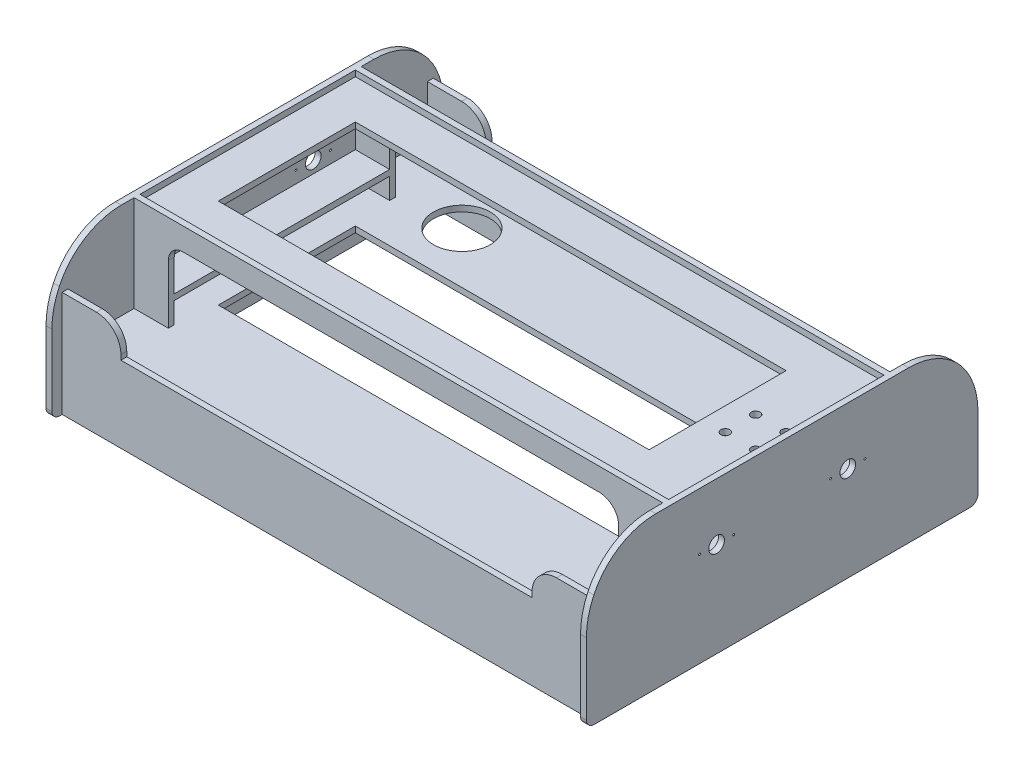
from build123d import *

# Parameters (mm, degrees)
SKETCH_2_W           = 432
SKETCH_2_H           = 220
EXTRUDE_2_DEPTH      = 6
SKETCH_4_W           = 6
SKETCH_4_H           = 28
EXTRUDE_3_DEPTH      = 432
EXTRUDE_4_DEPTH      = 108
SKETCH_6_W           = 540
SKETCH_6_H           = 6
EXTRUDE_5_DEPTH      = 25
EXTRUDE_6_DEPTH      = 6
EXTRUDE_7_DEPTH      = 6
SKETCH_9_W           = 367
SKETCH_9_H           = 6
EXTRUDE_8_DEPTH      = 540
SKETCH_10_R          = 8
CUT_EXTRUDE_1_DEPTH  = 553
SKETCH_11_W          = 6
SKETCH_11_H          = 108
EXTRUDE_9_DEPTH      = 546
SKETCH_12_W          = 70
SKETCH_12_H          = 127
SKETCH_12_W_2        = 195
CUT_EXTRUDE_2_DEPTH  = 6
SKETCH_13_R          = 29
SKETCH_13_W          = 42.3
SKETCH_13_H          = 42.3
CUT_EXTRUDE_3_DEPTH  = 10
SKETCH_14_W          = 220
SKETCH_14_H          = 6
EXTRUDE_10_DEPTH     = 45
SKETCH_15_R          = 16.4
SKETCH_15_R_2        = 1.5
CUT_EXTRUDE_4_DEPTH  = 6
SKETCH_16_R          = 4.5
CUT_EXTRUDE_5_DEPTH  = 6
FILLET_1_R           = 80
FILLET_2_R           = 8
SKETCH_18_W          = 6
SKETCH_18_H          = 75
EXTRUDE_11_DEPTH     = 45
SKETCH_19_W          = 420
SKETCH_19_H          = 30
SKETCH_19_W_2        = 540
CUT_EXTRUDE_8_DEPTH  = 390.5
FILLET_4_R           = 25
FILLET_6_R           = 20
SKETCH_20_W          = 6
SKETCH_20_H          = 75
EXTRUDE_12_DEPTH     = 35
FILLET_7_R           = 15
SKETCH_21_W          = 220
SKETCH_21_H          = 6
EXTRUDE_13_DEPTH     = 35
SKETCH_22_R          = 1
CUT_EXTRUDE_9_DEPTH  = 553
CUT_EXTRUDE_10_DEPTH = 58
SKETCH_24_W          = 440
SKETCH_24_H          = 140
CUT_EXTRUDE_11_DEPTH = 150
SKETCH_25_W          = 309.538461538
SKETCH_25_H          = 30
CUT_EXTRUDE_12_DEPTH = 553
FILLET_8_R           = 70


with BuildPart() as part:
    # Эскиз2 → Бобышка-Вытянуть2 (new body)
    with BuildSketch(Plane(origin=(0, 0, 0), x_dir=(1, 0, 0), z_dir=(0, 1, 0))):
        Rectangle(SKETCH_2_W, SKETCH_2_H)
    extrude(amount=EXTRUDE_2_DEPTH)

    # Эскиз4 → Бобышка-Вытянуть3 (add)
    with BuildSketch(Plane(origin=(216, 0, 0), x_dir=(0, 0, -1), z_dir=(1, 0, 0))):
        with Locations((-113, 3)):
            Rectangle(SKETCH_4_W, SKETCH_4_H)
        with Locations((113, 3)):
            Rectangle(SKETCH_4_W, SKETCH_4_H)
    extrude(amount=-EXTRUDE_3_DEPTH)

    # Эскиз5 → Бобышка-Вытянуть4 (add)
    with BuildSketch(Plane.ZY.offset(216)):
        Polygon((-116, 17), (-110, 17), (-110, 6), (110, 6), (110, 17), (116, 17), (116, -11), (110, -11), (110, 0), (-110, 0), (-110, -11), (-116, -11), align=None)
    extrude(amount=EXTRUDE_4_DEPTH)

    # Эскиз6 → Бобышка-Вытянуть5 (add)
    with BuildSketch(Plane(origin=(0, 17, 0), x_dir=(1, 0, 0), z_dir=(0, 1, 0))):
        with Locations((-54, -113)):
            Rectangle(SKETCH_6_W, SKETCH_6_H)
        with Locations((-54, 113)):
            Rectangle(SKETCH_6_W, SKETCH_6_H)
    extrude(amount=EXTRUDE_5_DEPTH)

    # Эскиз7 → Бобышка-Вытянуть6 (add)
    with BuildSketch(Plane(origin=(216, 0, 0), x_dir=(0, 0, -1), z_dir=(1, 0, 0))):
        Polygon((-200, -143), (-200, -23), (-116, 42), (116, 42), (200, -23), (200, -143), align=None)
    extrude(amount=EXTRUDE_6_DEPTH)

    # Эскиз8 → Бобышка-Вытянуть7 (add)
    with BuildSketch(Plane.ZY.offset(324)):
        Polygon((-116, 42), (-200, -23), (-200, -143), (200, -143), (200, -23), (116, 42), align=None)
    extrude(amount=EXTRUDE_7_DEPTH)

    # Эскиз9 → Бобышка-Вытянуть8 (add)
    with BuildSketch(Plane(origin=(-324, 0, 0), x_dir=(0, 0, -1), z_dir=(1, 0, 0))):
        with Locations((0, -89)):
            Rectangle(SKETCH_9_W, SKETCH_9_H)
    extrude(amount=EXTRUDE_8_DEPTH)

    # Эскиз10 → Вырез-Вытянуть1 (cut, through all)
    with BuildSketch(Plane.ZY.offset(330)):
        with Locations((67, -46.276194705)):
            Circle(SKETCH_10_R)
        with Locations((-67, -46.276194705)):
            Circle(SKETCH_10_R)
    extrude(amount=-CUT_EXTRUDE_1_DEPTH, mode=Mode.SUBTRACT)

    # Эскиз11 → Бобышка-Вытянуть9 (add)
    with BuildSketch(Plane(origin=(222, 0, 0), x_dir=(0, 0, -1), z_dir=(1, 0, 0))):
        with Locations((186.5, -89)):
            Rectangle(SKETCH_11_W, SKETCH_11_H)
        with Locations((-186.5, -89)):
            Rectangle(SKETCH_11_W, SKETCH_11_H)
    extrude(amount=-EXTRUDE_9_DEPTH)

    # Эскиз12 → Вырез-Вытянуть2 (cut)
    with BuildSketch(Plane(origin=(0, -92, 0), x_dir=(-1, 0, 0), z_dir=(0, -1, 0))):
        with Locations((234, 0)):
            Rectangle(SKETCH_12_W, SKETCH_12_H)
        with Locations((51.5, 0)):
            Rectangle(SKETCH_12_W_2, SKETCH_12_H)
        with Locations((-131, 0)):
            Rectangle(SKETCH_12_W, SKETCH_12_H)
    extrude(amount=-CUT_EXTRUDE_2_DEPTH, mode=Mode.SUBTRACT)

    # Эскиз13 → Вырез-Вытянуть3 (cut)
    with BuildSketch(Plane(origin=(0, -86, 0), x_dir=(1, 0, 0), z_dir=(0, 1, 0))):
        with Locations((-227.5, 122.3)):
            Circle(SKETCH_13_R)
        with Locations((194.85, 0)):
            Rectangle(SKETCH_13_W, SKETCH_13_H)
    extrude(amount=-CUT_EXTRUDE_3_DEPTH, mode=Mode.SUBTRACT)

    # Эскиз14 → Бобышка-Вытянуть10 (add)
    with BuildSketch(Plane.ZY.offset(-216)):
        with Locations((0, -61.5)):
            Rectangle(SKETCH_14_W, SKETCH_14_H)
    extrude(amount=EXTRUDE_10_DEPTH)

    # Эскиз15 → Вырез-Вытянуть4 (cut)
    with BuildSketch(Plane(origin=(0, -58.5, 0), x_dir=(1, 0, 0), z_dir=(0, 1, 0))):
        with Locations((194.85, 0)):
            Circle(SKETCH_15_R)
        with Locations((179.35, 15.5)):
            Circle(SKETCH_15_R_2)
        with Locations((210.35, 15.5)):
            Circle(SKETCH_15_R_2)
        with Locations((210.35, -15.5)):
            Circle(SKETCH_15_R_2)
        with Locations((179.35, -15.5)):
            Circle(SKETCH_15_R_2)
    extrude(amount=-CUT_EXTRUDE_4_DEPTH, mode=Mode.SUBTRACT)

    # Эскиз16 → Вырез-Вытянуть5 (cut)
    with BuildSketch(Plane(origin=(0, 6, 0), x_dir=(1, 0, 0), z_dir=(0, 1, 0))):
        with Locations((179.35, 15.5)):
            Circle(SKETCH_16_R)
        with Locations((210.35, 15.5)):
            Circle(SKETCH_16_R)
        with Locations((179.35, -15.5)):
            Circle(SKETCH_16_R)
        with Locations((210.35, -15.5)):
            Circle(SKETCH_16_R)
    extrude(amount=-CUT_EXTRUDE_5_DEPTH, mode=Mode.SUBTRACT)

    # Скругление1
    fillet_1_edges = [part.edges().sort_by_distance(p)[0] for p in [
        (219, -23, -200),
        (219, -23, 200),
        (-327, -23, -200),
        (-327, -23, 200),
    ]]
    fillet(fillet_1_edges, radius=FILLET_1_R)

    # Скругление2
    fillet_2_edges = [part.edges().sort_by_distance(p)[0] for p in [
        (219, -143, 200),
        (219, -143, -200),
        (-327, -143, -200),
        (-327, -143, 200),
    ]]
    fillet(fillet_2_edges, radius=FILLET_2_R)

    # Эскиз18 → Бобышка-Вытянуть11 (add)
    with BuildSketch(Plane.ZY.offset(-216)):
        with Locations((113, -48.5)):
            Rectangle(SKETCH_18_W, SKETCH_18_H)
        with Locations((-113, -48.5)):
            Rectangle(SKETCH_18_W, SKETCH_18_H)
    extrude(amount=EXTRUDE_11_DEPTH)

    # Эскиз19 → Вырез-Вытянуть8 (cut, through all)
    with BuildSketch(Plane.XY.offset(189.5)):
        with Locations((-54, -50)):
            Rectangle(SKETCH_19_W, SKETCH_19_H)
        with Locations((-54, 27)):
            Rectangle(SKETCH_19_W_2, SKETCH_19_H)
    extrude(amount=-CUT_EXTRUDE_8_DEPTH, mode=Mode.SUBTRACT)

    # Скругление4
    fillet_4_edges = [part.edges().sort_by_distance(p)[0] for p in [
        (-264, -35, -186.5),
        (156, -35, -186.5),
        (-264, -35, 186.5),
        (156, -35, 186.5),
    ]]
    fillet(fillet_4_edges, radius=FILLET_4_R)

    # Скругление6
    fillet_6_edges = [part.edges().sort_by_distance(p)[0] for p in [
        (171, -11, 113),
        (171, -11, -113),
    ]]
    fillet(fillet_6_edges, radius=FILLET_6_R)

    # Эскиз20 → Бобышка-Вытянуть12 (add)
    with BuildSketch(Plane(origin=(-324, 0, 0), x_dir=(0, 0, -1), z_dir=(1, 0, 0))):
        with Locations((-113, -48.5)):
            Rectangle(SKETCH_20_W, SKETCH_20_H)
        with Locations((113, -48.5)):
            Rectangle(SKETCH_20_W, SKETCH_20_H)
    extrude(amount=EXTRUDE_12_DEPTH)

    # Скругление7
    fillet_7_edges = [part.edges().sort_by_distance(p)[0] for p in [
        (-289, -11, 113),
        (-289, -11, -113),
    ]]
    fillet(fillet_7_edges, radius=FILLET_7_R)

    # Эскиз21 → Бобышка-Вытянуть13 (add)
    with BuildSketch(Plane(origin=(-324, 0, 0), x_dir=(0, 0, -1), z_dir=(1, 0, 0))):
        with Locations((0, -61.5)):
            Rectangle(SKETCH_21_W, SKETCH_21_H)
    extrude(amount=EXTRUDE_13_DEPTH)

    # Эскиз22 → Вырез-Вытянуть9 (cut, through all)
    with BuildSketch(Plane(origin=(222, 0, 0), x_dir=(0, 0, -1), z_dir=(1, 0, 0))):
        with Locations((84.5, -46.276194705)):
            Circle(SKETCH_22_R)
        with Locations((49.5, -46.276194705)):
            Circle(SKETCH_22_R)
        with Locations((-49.5, -46.276194705)):
            Circle(SKETCH_22_R)
        with Locations((-84.5, -46.276194705)):
            Circle(SKETCH_22_R)
    extrude(amount=-CUT_EXTRUDE_9_DEPTH, mode=Mode.SUBTRACT)

    # Эскиз23 → Вырез-Вытянуть10 (cut, through all)
    with BuildSketch(Plane(origin=(0, -86, 0), x_dir=(1, 0, 0), z_dir=(0, 1, 0))):
        with BuildLine():
            Line((174.514215804, -139.4), (164.514215804, -139.4))
            ThreePointArc((164.514215804, -139.4), (164.014215804, -138.9), (164.514215804, -138.4))
            Line((164.514215804, -138.4), (174.514215804, -138.4))
            ThreePointArc((174.514215804, -138.4), (175.014215804, -138.9), (174.514215804, -139.4))
        make_face()
        with BuildLine():
            Line((174.514215804, -148.9), (164.514215804, -148.9))
            ThreePointArc((164.514215804, -148.9), (164.014215804, -148.4), (164.514215804, -147.9))
            Line((164.514215804, -147.9), (174.514215804, -147.9))
            ThreePointArc((174.514215804, -147.9), (175.014215804, -148.4), (174.514215804, -148.9))
        make_face()
    extrude(amount=-CUT_EXTRUDE_10_DEPTH, mode=Mode.SUBTRACT)

    # Эскиз24 → Вырез-Вытянуть11 (cut, through all)
    with BuildSketch(Plane(origin=(0, 6, 0), x_dir=(1, 0, 0), z_dir=(0, 1, 0))):
        with Locations((-64, 0)):
            Rectangle(SKETCH_24_W, SKETCH_24_H)
    extrude(amount=-CUT_EXTRUDE_11_DEPTH, mode=Mode.SUBTRACT)

    # Эскиз25 → Вырез-Вытянуть12 (cut, through all)
    with BuildSketch(Plane.ZY.offset(330)):
        with Locations((0, 27)):
            Rectangle(SKETCH_25_W, SKETCH_25_H)
    extrude(amount=-CUT_EXTRUDE_12_DEPTH, mode=Mode.SUBTRACT)

    # Скругление8
    fillet_8_edges = [part.edges().sort_by_distance(p)[0] for p in [
        (-327, 12, 154.769230769),
        (-327, 12, -154.769230769),
        (219, 12, -154.769230769),
        (219, 12, 154.769230769),
    ]]
    fillet(fillet_8_edges, radius=FILLET_8_R)


solid = part.part
